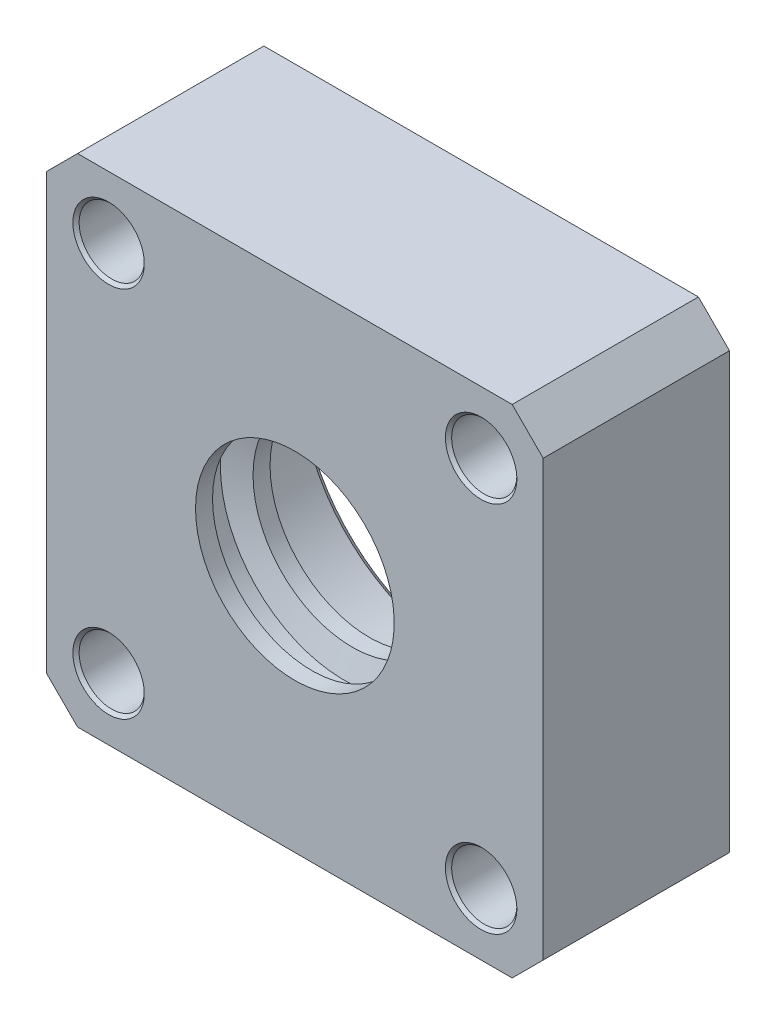
from build123d import *

# Parameters (mm, degrees)
SKETCH1_W                        = 80
SKETCH1_H                        = 80
BOSS_EXTRUDE1_DEPTH              = 30
M56_CLEARANCE_HOLE1_D            = 66
M56_CLEARANCE_HOLE1_DEPTH        = 4.4
SKETCH4_W                        = 3
SKETCH4_H                        = 2
SKETCH5_W                        = 30
SKETCH5_H                        = 2.4
F_10_5_10_5_DIAMETER_HOLE1_D     = 10.5
F_10_5_10_5_DIAMETER_HOLE1_DEPTH = 30
F_10_5_10_5_DIAMETER_HOLE2_D     = 10.5
F_10_5_10_5_DIAMETER_HOLE2_DEPTH = 30
CHAMFER1_SIZE                    = 5
CHAMFER2_SIZE                    = 0.5
CHAMFER3_SIZE                    = 1.2
SCALE1_SCALE                     = 0.75


with BuildPart() as part:
    # Sketch1 → Boss-Extrude1 (new body)
    with BuildSketch(Plane(origin=(0, 0, 0), x_dir=(-1, 0, 0), z_dir=(0, 0, -1))):
        Rectangle(SKETCH1_W, SKETCH1_H)
    extrude(amount=-BOSS_EXTRUDE1_DEPTH)

    # M56 Clearance Hole1
    with Locations(Plane(origin=(0, 0, 0), x_dir=(-1, 0, 0), z_dir=(0, 0, -1))):
        with Locations((0, 0)):
            Hole(M56_CLEARANCE_HOLE1_D / 2, depth=M56_CLEARANCE_HOLE1_DEPTH)

    # Sketch4 → Cut-Revolve1 (revolve, cut)
    with BuildSketch(Plane.XZ):
        with Locations((34.5, 1)):
            Rectangle(SKETCH4_W, SKETCH4_H)
    revolve(axis=Axis((0, 0, 2), (0, 0, -1)), mode=Mode.SUBTRACT)

    # Sketch5 → Revolve1 (revolve)
    with BuildSketch(Plane.XZ):
        with Locations((15, 3.2)):
            Rectangle(SKETCH5_W, SKETCH5_H)
    revolve(axis=Axis((0, 0, 4.4), (0, 0, -1)))

    # Sketch6 → Cut-Revolve2 (revolve, cut)
    with BuildSketch(Plane.XZ):
        Polygon((16, 30), (0, 30), (0, 2), (26, 2), (26, 17), (22, 17), (22, 18), (16, 18), (16, 20.738804844), (20, 22), (20, 26), (16, 27.261195156), align=None)
    revolve(axis=Axis((0, 0, 30), (0, 0, -1)), mode=Mode.SUBTRACT)

    # Ø10.5 (10.5) Diameter Hole1
    with Locations(Plane.XY.offset(30)):
        with Locations((-30, -30), (30, 30)):
            Hole(F_10_5_10_5_DIAMETER_HOLE1_D / 2, depth=F_10_5_10_5_DIAMETER_HOLE1_DEPTH)

    # Ø10.5 (10.5) Diameter Hole2
    with Locations(Plane(origin=(0, 0, 0), x_dir=(-1, 0, 0), z_dir=(0, 0, -1))):
        with Locations((30, 30), (-30, -30)):
            Hole(F_10_5_10_5_DIAMETER_HOLE2_D / 2, depth=F_10_5_10_5_DIAMETER_HOLE2_DEPTH)

    # Chamfer1
    chamfer1_edges = [part.edges().sort_by_distance(p)[0] for p in [
        (-40, -40, 15),
        (40, -40, 15),
        (40, 40, 15),
        (-40, 40, 15),
    ]]
    chamfer(chamfer1_edges, length=CHAMFER1_SIZE)

    # Chamfer2
    chamfer2_edges = [part.edges().sort_by_distance(p)[0] for p in [
        (35.25, 30, 30),
        (35.25, 30, 0),
        (-24.75, -30, 30),
        (-24.75, -30, 0),
        (24.75, -30, 0),
        (24.75, -30, 30),
        (-35.25, 30, 0),
        (-35.25, 30, 30),
    ]]
    chamfer(chamfer2_edges, length=CHAMFER2_SIZE)

    # Chamfer3
    chamfer3_edges = [part.edges().sort_by_distance(p)[0] for p in [
        (-26, 0, 2),
    ]]
    chamfer(chamfer3_edges, length=CHAMFER3_SIZE)


with BuildPart() as part_1:
    # Scale1: scaled about (0, 0, 16.565087269)
    add(part.part.scale(SCALE1_SCALE).moved(Location((0, 0, 4.141271817))))


solid = part_1.part
